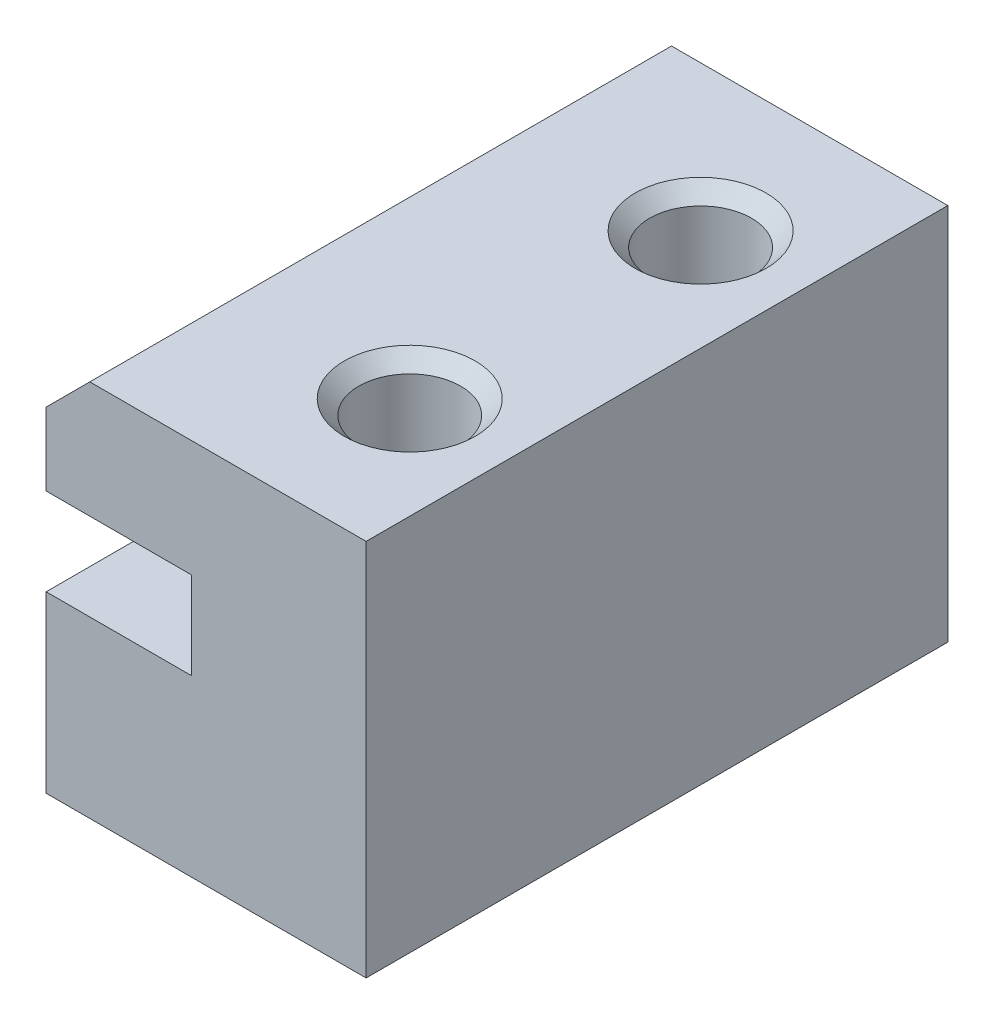
from build123d import *

# Parameters (mm, degrees)
BOSS_EXTRUDE1_DEPTH = 10
SKETCH2_R           = 1.75
CUT_EXTRUDE1_DEPTH  = 14
CHAMFER1_SIZE       = 1.5
SKETCH3_W           = 5
SKETCH3_H           = 13
CUT_EXTRUDE2_DEPTH  = 21
SKETCH4_W           = 20
SKETCH4_H           = 13
BOSS_EXTRUDE2_DEPTH = 1
CHAMFER3_SIZE       = 0.5


with BuildPart() as part:
    # Sketch1 → Boss-Extrude1 (new body, symmetric)
    with BuildSketch(Plane.XY):
        Polygon((0, 0), (15, 0), (15, 6), (10, 6), (10, 9), (15, 9), (15, 13), (0, 13), (0, 9), (5, 9), (5, 6), (0, 6), align=None)
    extrude(amount=BOSS_EXTRUDE1_DEPTH, both=True)

    # Sketch2 → Cut-Extrude1 (cut, through all)
    with BuildSketch(Plane(origin=(0, 13, 0), x_dir=(1, 0, 0), z_dir=(0, 1, 0))):
        with Locations((7.5, -5)):
            Circle(SKETCH2_R)
        with Locations((7.5, 5)):
            Circle(SKETCH2_R)
    extrude(amount=-CUT_EXTRUDE1_DEPTH, mode=Mode.SUBTRACT)

    # Chamfer1
    chamfer1_edges = [part.edges().sort_by_distance(p)[0] for p in [
        (0, 13, 0),
        (15, 13, 0),
    ]]
    chamfer(chamfer1_edges, length=CHAMFER1_SIZE)

    # Sketch3 → Cut-Extrude2 (cut, through all)
    with BuildSketch(Plane.XY.offset(10)):
        with Locations((12.5, 6.5)):
            Rectangle(SKETCH3_W, SKETCH3_H)
    extrude(amount=-CUT_EXTRUDE2_DEPTH, mode=Mode.SUBTRACT)

    # Sketch4 → Boss-Extrude2 (add)
    with BuildSketch(Plane(origin=(10, 0, 0), x_dir=(0, 0, -1), z_dir=(1, 0, 0))):
        with Locations((0, 6.5)):
            Rectangle(SKETCH4_W, SKETCH4_H)
    extrude(amount=BOSS_EXTRUDE2_DEPTH)

    # Chamfer3
    chamfer3_edges = [part.edges().sort_by_distance(p)[0] for p in [
        (5.75, 13, 5),
        (5.75, 13, -5),
    ]]
    chamfer(chamfer3_edges, length=CHAMFER3_SIZE)


solid = part.part
